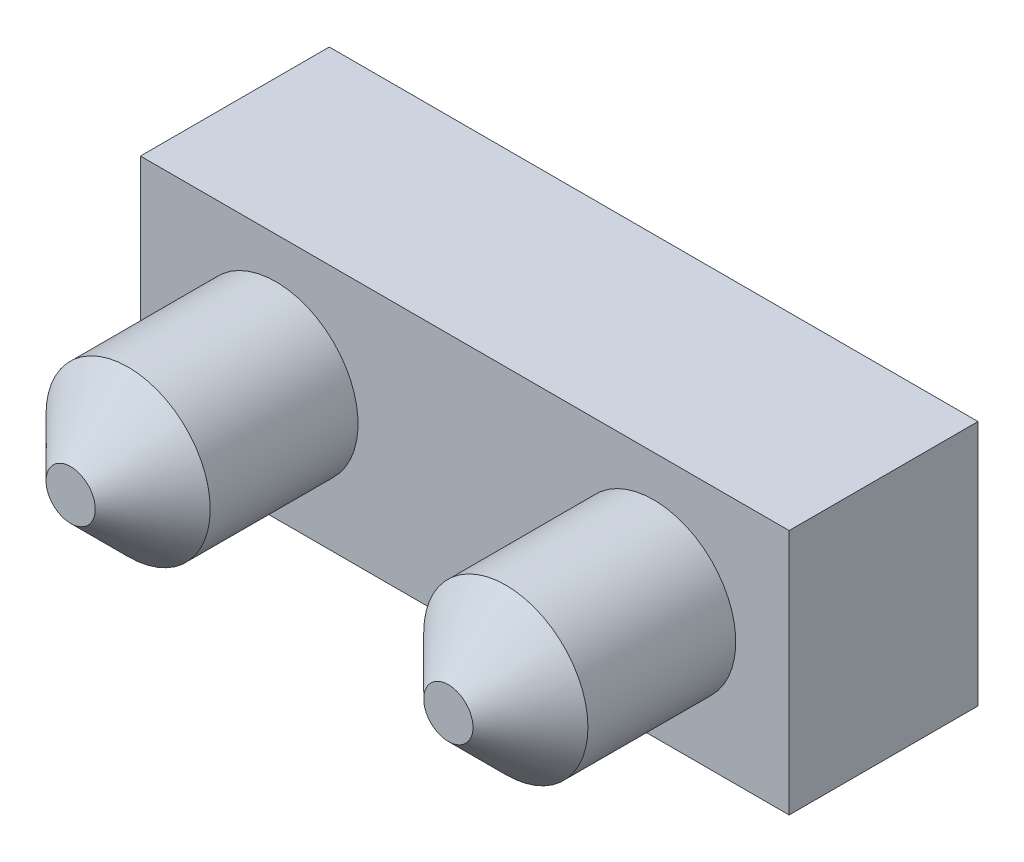
from build123d import *

# Parameters (mm, degrees)
SKICA1_W                = 7.9
SKICA1_H                = 3
P_IDAT_VYSUNUT_M1_DEPTH = 2.3
SKICA2_R                = 1
P_IDAT_VYSUNUT_M2_DEPTH = 2.5
ZKOSEN_2_SIZE           = 0.7


with BuildPart() as part:
    # Skica1 → Přidat vysunutím1 (new body)
    with BuildSketch(Plane.XY):
        Rectangle(SKICA1_W, SKICA1_H)
    extrude(amount=P_IDAT_VYSUNUT_M1_DEPTH)

    # Skica2 → Přidat vysunutím2 (add)
    with BuildSketch(Plane.XY.offset(2.3)):
        with Locations((-2.3, 0)):
            Circle(SKICA2_R)
        with Locations((2.3, 0)):
            Circle(SKICA2_R)
    extrude(amount=P_IDAT_VYSUNUT_M2_DEPTH)

    # Zkosení2
    zkosen_2_edges = [part.edges().sort_by_distance(p)[0] for p in [
        (-3.3, 0, 4.8),
        (1.3, 0, 4.8),
    ]]
    chamfer(zkosen_2_edges, length=ZKOSEN_2_SIZE)


solid = part.part
